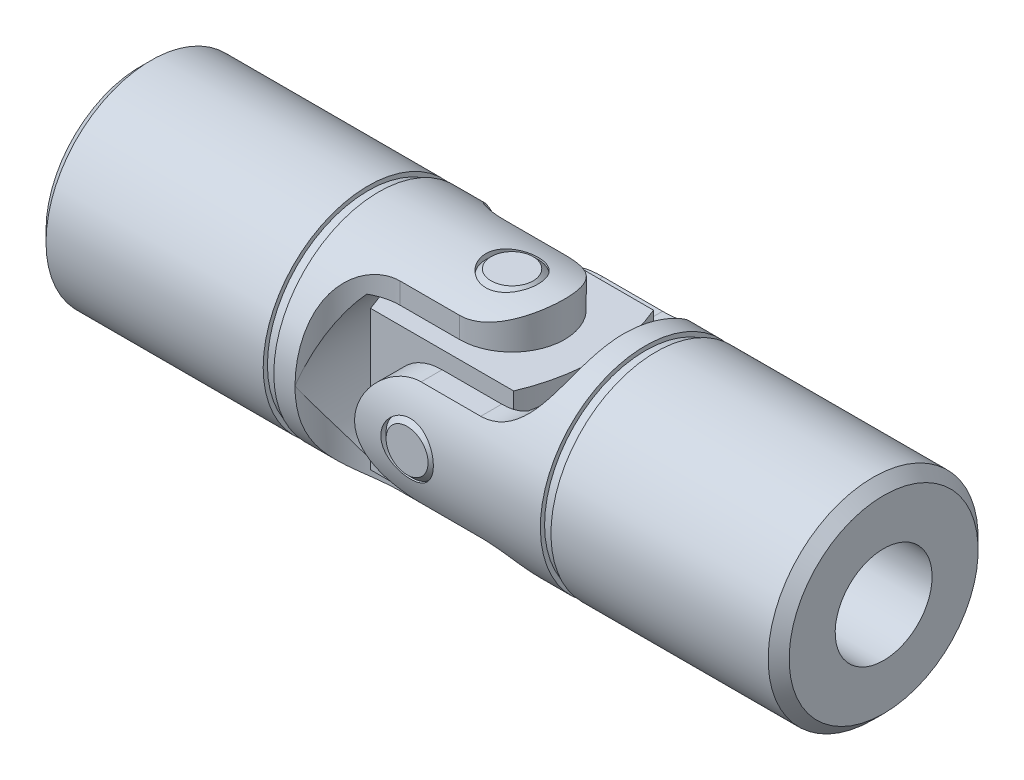
from build123d import *

# Parameters (mm, degrees)
CHAMFER1_SIZE               = 1.031875
EXTRUDE1_DEPTH              = 40.320679793
EXTRUDE1_DEPTH_BACK         = 40.320679793
EXTRUDE3_DEPTH              = 40.320679845
EXTRUDE3_DEPTH_BACK         = 40.320679845
SKETCH4_R                   = 4.7625
EXTRUDE4_DEPTH              = 22.225
EXTRUDE6_DEPTH              = 40.320679845
EXTRUDE6_DEPTH_BACK         = 40.320679845
SKETCH6_R                   = 2.5796875
BODY_MOVE_COPY1_ANGLE       = 90
EXTRUDE10_REACH             = 41.321
SKETCH10_W                  = 16.8671875
SKETCH10_H                  = 13.744575
EXTRUDE10_DIRECTION_2_REACH = 41.321
CUT_EXTRUDE2_DEPTH          = 42.655384209
EXTRUDE13_DEPTH             = 40.320679845
EXTRUDE13_DEPTH_BACK        = 40.320679845
SKETCH13_R                  = 2.5796875
SKETCH14_R                  = 2.5796875
EXTRUDE14_DEPTH             = 10.31875
EXTRUDE15_DEPTH             = 40.320679845
EXTRUDE15_DEPTH_BACK        = 40.320679845
SKETCH15_R                  = 2.5796875
SKETCH16_R                  = 2.5796875
EXTRUDE16_DEPTH             = 10.31875
CHAMFER3_SIZE               = 0.5159375


with BuildPart() as part:
    # Sketch1 → Revolve1 (revolve)
    with BuildSketch(Plane(origin=(0, 0, 0), x_dir=(1, 0, 0), z_dir=(0, 1, 0)), mode=Mode.PRIVATE) as revolve1_sk:
        Polygon((-36.5125, 10.31875), (-14.138671875, 10.31875), (-14.138671875, 9.90203125), (-13.096875, 9.90203125), (-13.096875, 10.31875), (5.159375, 10.31875), (5.159375, 0), (-36.5125, 0), align=None)
    revolve(revolve1_sk.sketch.rotate(Axis((-36.5125, 0, 0), (1, 0, 0)), 180), axis=Axis((-36.5125, 0, 0), (1, 0, 0)))

    # Chamfer1
    chamfer1_edges = [part.edges().sort_by_distance(p)[0] for p in [
        (-36.5125, 0, -10.31875),
    ]]
    chamfer(chamfer1_edges, length=CHAMFER1_SIZE)

    # Sketch2 → Extrude1 (cut, two sides: drawn at the far end of the back side and taken through both)
    with BuildSketch(Plane(origin=(0, 0, 0), x_dir=(1, 0, 0), z_dir=(0, 1, 0)).offset(-EXTRUDE1_DEPTH_BACK)):
        with BuildLine():
            Line((-11.01328125, 10.31875), (10.31875, 10.31875))
            Line((10.31875, 10.31875), (10.31875, -10.31875))
            Line((10.31875, -10.31875), (-11.01328125, -10.31875))
            ThreePointArc((-11.01328125, -10.31875), (-9.502135299, -6.670520951), (-5.85390625, -5.159375))
            Line((-5.85390625, -5.159375), (0, -5.159375))
            ThreePointArc((0, -5.159375), (5.159375, 0), (0, 5.159375))
            Line((0, 5.159375), (-5.85390625, 5.159375))
            ThreePointArc((-5.85390625, 5.159375), (-9.502135299, 6.670520951), (-11.01328125, 10.31875))
        make_face()
    extrude(amount=EXTRUDE1_DEPTH + EXTRUDE1_DEPTH_BACK, mode=Mode.SUBTRACT)

    # Sketch3 → Extrude3 (cut, two sides: drawn at the far end of the back side and taken through both)
    with BuildSketch(Plane.XY.offset(-EXTRUDE3_DEPTH_BACK)):
        with BuildLine():
            Line((-8.43359375, 6.8722875), (10.31875, 6.8722875))
            Line((10.31875, 6.8722875), (10.31875, -6.8722875))
            Line((10.31875, -6.8722875), (-8.43359375, -6.8722875))
            ThreePointArc((-8.43359375, -6.8722875), (-11.01328125, 0), (-8.43359375, 6.8722875))
        make_face()
    extrude(amount=EXTRUDE3_DEPTH + EXTRUDE3_DEPTH_BACK, mode=Mode.SUBTRACT)

    # Sketch4 → Extrude4 (cut)
    with BuildSketch(Plane.ZY.offset(36.5125)):
        Circle(SKETCH4_R)
    extrude(amount=-EXTRUDE4_DEPTH, mode=Mode.SUBTRACT)

    # Extrude5 cone 1 section (through the dimple's axis) → Extrude5 (revolve, cut)
    with BuildSketch(Plane(origin=(-14.2875, 0, 0), x_dir=(0, 0, 1), z_dir=(0, 1, 0))):
        Polygon((0, 0), (4.7625, 0), (0, 4.7625), align=None)
    revolve(axis=Axis((-14.2875, 0, 0), (1, 0, 0)), mode=Mode.SUBTRACT)

    # Sketch6 → Extrude6 (cut, two sides: drawn at the far end of the back side and taken through both)
    with BuildSketch(Plane(origin=(0, 0, 0), x_dir=(1, 0, 0), z_dir=(0, 1, 0)).offset(-EXTRUDE6_DEPTH_BACK)):
        with Locations(Location((0, 0, 0), (0, 0, 270))):
            Circle(SKETCH6_R)
    extrude(amount=EXTRUDE6_DEPTH + EXTRUDE6_DEPTH_BACK, mode=Mode.SUBTRACT)


with BuildPart() as body_2:
    # Mirror1: mirrored copy
    add(part.part.mirror(Plane(origin=(0, 0, 0), x_dir=(0, 0, 1), z_dir=(1, 0, 0))))


with BuildPart() as body_2_1:
    # Body-Move/Copy1: moved
    add(body_2.part.rotate(Axis((0, 0, 0), (1, 0, 0)), BODY_MOVE_COPY1_ANGLE))


with BuildPart() as body_3:

    # Extrude10: up to this face of the body (flat: up to its plane)
    extrude10_end = Plane(body_2_1.part.faces().sort_by_distance((2.607218379, 0, -6.8722875))[0])
    # Sketch10 → Extrude10 (new, up to the picked face)
    with BuildSketch(Plane.XY, mode=Mode.PRIVATE) as extrude10_sk1:
        Rectangle(SKETCH10_W, SKETCH10_H)
    extrude10_tool1 = split(extrude(extrude10_sk1.sketch, amount=-EXTRUDE10_REACH, mode=Mode.PRIVATE), bisect_by=extrude10_end, keep=Keep.BOTH, mode=Mode.PRIVATE)
    add(extrude10_tool1.solids().sort_by(Axis((0, 0, 0), (0, 0, -1)))[0])


    # Extrude10 direction 2: up to this face of the body (flat: up to its plane)
    extrude10_direction_2_end = Plane(body_2_1.part.faces().sort_by_distance((2.607218379, 0, 6.8722875))[0])
    # Sketch10 → Extrude10 direction 2 (add, up to the picked face)
    with BuildSketch(Plane.XY, mode=Mode.PRIVATE) as extrude10_direction_2_sk1:
        Rectangle(SKETCH10_W, SKETCH10_H)
    extrude10_direction_2_tool1 = split(extrude(extrude10_direction_2_sk1.sketch, amount=EXTRUDE10_DIRECTION_2_REACH, mode=Mode.PRIVATE), bisect_by=extrude10_direction_2_end, keep=Keep.BOTH, mode=Mode.PRIVATE)
    add(extrude10_direction_2_tool1.solids().sort_by(Axis((0, 0, 0), (0, 0, 1)))[0])

    # Sketch20 → Cut-Extrude2 (cut, through all)
    with BuildSketch(Plane(origin=(0, 6.8722875, 0), x_dir=(1, 0, 0), z_dir=(0, 1, 0))):
        with BuildLine():
            Line((9.44959375, -7.8882875), (9.44959375, 7.8882875))
            Line((9.44959375, 7.8882875), (7.027994792, 7.8882875))
            Line((7.027994792, 7.8882875), (7.027994792, 6.8722875))
            ThreePointArc((7.027994792, 6.8722875), (8.43359375, 0), (7.027994792, -6.8722875))
            Line((7.027994792, -6.8722875), (7.027994792, -7.8882875))
            Line((7.027994792, -7.8882875), (9.44959375, -7.8882875))
        make_face()
        with BuildLine():
            Line((-9.44959375, 7.8882875), (-9.44959375, -7.8882875))
            Line((-9.44959375, -7.8882875), (-7.027994792, -7.8882875))
            Line((-7.027994792, -7.8882875), (-7.027994792, -6.8722875))
            ThreePointArc((-7.027994792, -6.8722875), (-8.43359375, 0), (-7.027994792, 6.8722875))
            Line((-7.027994792, 6.8722875), (-7.027994792, 7.8882875))
            Line((-7.027994792, 7.8882875), (-9.44959375, 7.8882875))
        make_face()
    extrude(amount=-CUT_EXTRUDE2_DEPTH, mode=Mode.SUBTRACT)

    # Sketch13 → Extrude13 (cut, two sides: drawn at the far end of the back side and taken through both)
    with BuildSketch(Plane(origin=(0, 0, 0), x_dir=(1, 0, 0), z_dir=(0, 1, 0)).offset(-EXTRUDE13_DEPTH_BACK)):
        with Locations(Location((0, 0, 0), (0, 0, 180))):
            Circle(SKETCH13_R)
    extrude(amount=EXTRUDE13_DEPTH + EXTRUDE13_DEPTH_BACK, mode=Mode.SUBTRACT)

    # Sketch15 → Extrude15 (cut, two sides: drawn at the far end of the back side and taken through both)
    with BuildSketch(Plane.XY.offset(-EXTRUDE15_DEPTH_BACK)):
        Circle(SKETCH15_R)
    extrude(amount=EXTRUDE15_DEPTH + EXTRUDE15_DEPTH_BACK, mode=Mode.SUBTRACT)


with BuildPart() as body_4:
    # Sketch14 → Extrude14 (new, symmetric)
    with BuildSketch(Plane(origin=(0, 0, 0), x_dir=(1, 0, 0), z_dir=(0, 1, 0))):
        with Locations(Location((0, 0, 0), (0, 0, 270))):
            Circle(SKETCH14_R)
    extrude(amount=EXTRUDE14_DEPTH, both=True)

    # Sketch16 → Extrude16 (add, symmetric)
    with BuildSketch(Plane.XY):
        Circle(SKETCH16_R)
    extrude(amount=EXTRUDE16_DEPTH, both=True)

    # Chamfer3
    chamfer3_edges = [body_4.edges().sort_by_distance(p)[0] for p in [
        (0, -10.31875, -2.5796875),
        (0, 10.31875, -2.5796875),
        (-2.5796875, 0, -10.31875),
        (-2.5796875, 0, 10.31875),
    ]]
    chamfer(chamfer3_edges, length=CHAMFER3_SIZE)


solid = Compound([part.part, body_2_1.part, body_3.part, body_4.part])
